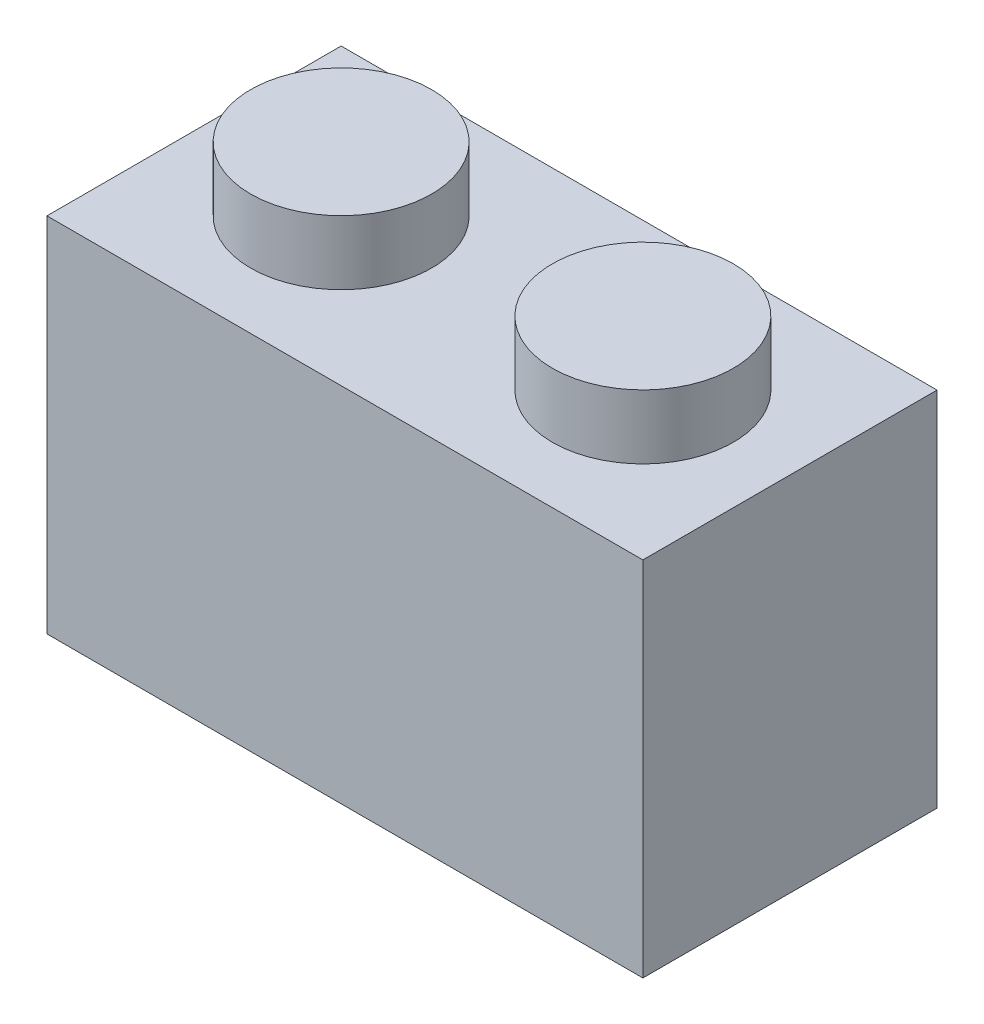
from build123d import *

# Parameters (mm, degrees)
SKETCH_1_W          = 15.8
SKETCH_1_H          = 7.8
EXTRUDE_1_DEPTH     = 9.6
SKETCH_2_R          = 2.4
EXTRUDE_2_DEPTH     = 1.7
SKETCH_3_R          = 2.5
CUT_EXTRUDE_1_DEPTH = 1.8


with BuildPart() as part:
    # Эскиз1 → Бобышка-Вытянуть1 (new body)
    with BuildSketch(Plane(origin=(0, 0, 0), x_dir=(1, 0, 0), z_dir=(0, 1, 0))):
        with Locations((7.9, 3.9)):
            Rectangle(SKETCH_1_W, SKETCH_1_H)
    extrude(amount=EXTRUDE_1_DEPTH)

    # Эскиз2 → Бобышка-Вытянуть2 (add)
    with BuildSketch(Plane(origin=(0, 9.6, 0), x_dir=(1, 0, 0), z_dir=(0, 1, 0))):
        with Locations((3.9, 3.9)):
            Circle(SKETCH_2_R)
        with Locations((11.9, 3.9)):
            Circle(SKETCH_2_R)
    extrude(amount=EXTRUDE_2_DEPTH)

    # Эскиз3 → Вырез-Вытянуть1 (cut)
    with BuildSketch(Plane.XZ):
        with Locations((11.9, -3.9)):
            Circle(SKETCH_3_R)
        with Locations((3.9, -3.9)):
            Circle(SKETCH_3_R)
    extrude(amount=-CUT_EXTRUDE_1_DEPTH, mode=Mode.SUBTRACT)


solid = part.part
